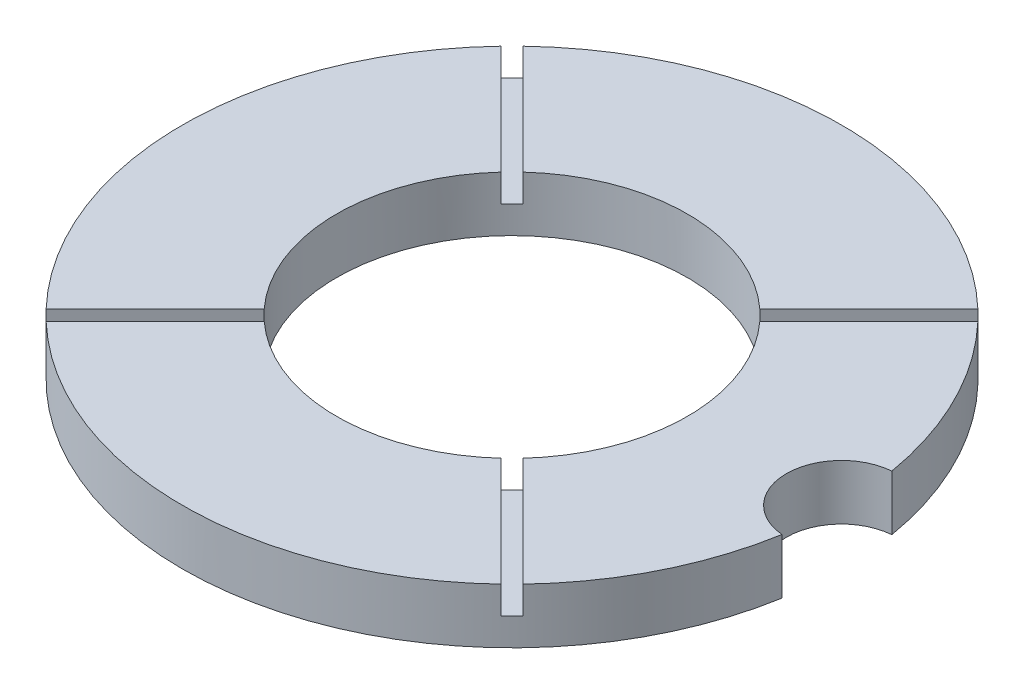
from build123d import *

# Parameters (mm, degrees)
SKETCH1_R           = 75.9206
BOSS_EXTRUDE1_DEPTH = 12.7
SKETCH1_10_R        = 40.4114
CUT_EXTRUDE2_DEPTH  = 13.7
SKETCH2_R           = 12.7
CUT_EXTRUDE3_DEPTH  = 13.7
CUT_EXTRUDE5_DEPTH  = 6.35


with BuildPart() as part:
    # Sketch1 → Boss-Extrude1 (new body)
    with BuildSketch(Plane(origin=(0, 0, 0), x_dir=(1, 0, 0), z_dir=(0, 1, 0))):
        Circle(SKETCH1_R)
    extrude(amount=BOSS_EXTRUDE1_DEPTH)

    # Sketch1_10 → Cut-Extrude2 (cut, through all)
    with BuildSketch(Plane(origin=(0, 0, 0), x_dir=(1, 0, 0), z_dir=(0, 1, 0))):
        Circle(SKETCH1_10_R)
    extrude(amount=CUT_EXTRUDE2_DEPTH, mode=Mode.SUBTRACT)

    # Sketch2 → Cut-Extrude3 (cut, through all)
    with BuildSketch(Plane(origin=(0, 12.7, 0), x_dir=(1, 0, 0), z_dir=(0, 1, 0))):
        with Locations((75.9206, 0)):
            Circle(SKETCH2_R)
    extrude(amount=-CUT_EXTRUDE3_DEPTH, mode=Mode.SUBTRACT)

    # Sketch3 → Cut-Extrude5 (cut)
    with BuildSketch(Plane(origin=(0, 12.7, 0), x_dir=(1, 0, 0), z_dir=(0, 1, 0))):
        Polygon((-28.180043708, 25.701493018), (-25.701493019, 28.180043708), (-60.52670499, 63.00525568), (-63.00525568, 60.52670499), align=None)
        Polygon((28.180043708, 25.701493019), (63.00525568, 60.52670499), (60.52670499, 63.00525568), (25.701493019, 28.180043708), align=None)
        Polygon((25.701493019, -28.180043708), (60.52670499, -63.00525568), (63.00525568, -60.52670499), (28.180043708, -25.701493018), align=None)
        Polygon((-28.180043708, -25.701493019), (-63.00525568, -60.52670499), (-60.52670499, -63.00525568), (-25.701493018, -28.180043708), align=None)
    extrude(amount=-CUT_EXTRUDE5_DEPTH, mode=Mode.SUBTRACT)


solid = part.part
